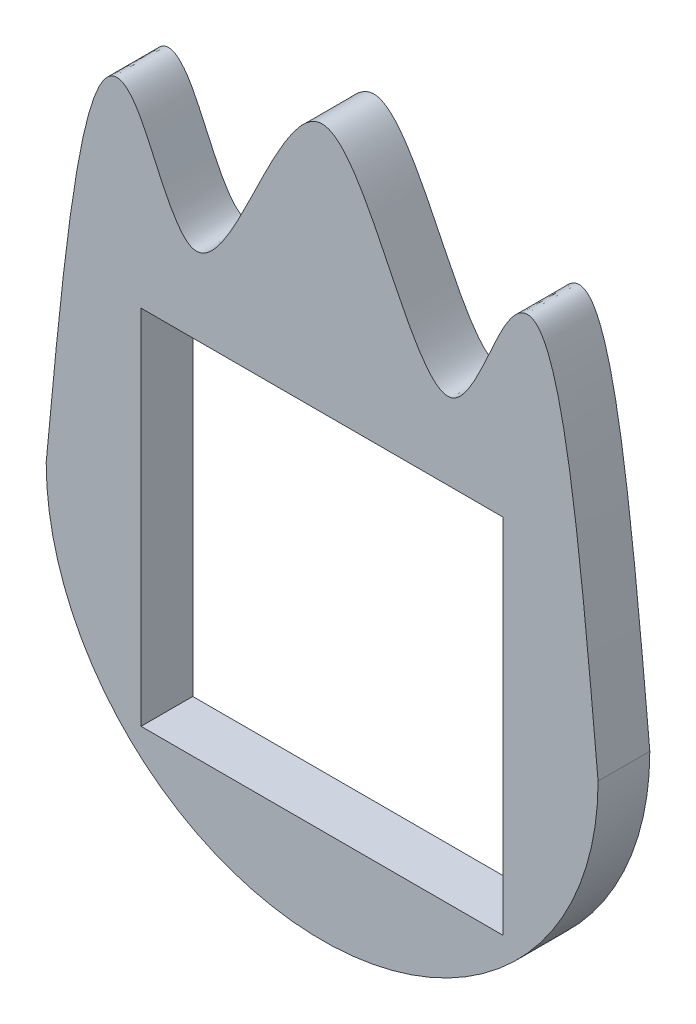
from build123d import *

# Parameters (mm, degrees)
MODEL_W             = 42
MODEL_H             = 42
BOSS_EXTRUDE1_DEPTH = 6


with BuildPart() as part:
    # Model → Boss-Extrude1 (new body)
    with BuildSketch(Plane.XY):
        with BuildLine():
            ThreePointArc((14.016231129, 39.924611058), (46.016231129, 7.924611058), (78.016231129, 39.924611058))
            add(Edge.make_bspline(
                [(14.016231129, 39.924611058), (16.420544727, 65.613232973), (19.500739159, 98.523228685), (30.98275806, 64.031256921), (38.567949025, 80.286022583), (46.016231129, 94.743905296), (53.464513232, 80.286022583), (61.049704197, 64.031256921), (72.531723098, 98.523228685), (75.611917531, 65.613232973), (78.016231129, 39.924611058)],
                knots=[0, 0, 0, 0, 0.265429393, 0.340044717, 0.420022359, 0.5, 0.579977641, 0.659955283, 0.734570607, 1, 1, 1, 1], degree=3))
        make_face()
        with Locations((46.016231129, 39.924611058)):
            Rectangle(MODEL_W, MODEL_H, mode=Mode.SUBTRACT)
    extrude(amount=BOSS_EXTRUDE1_DEPTH)


solid = part.part
